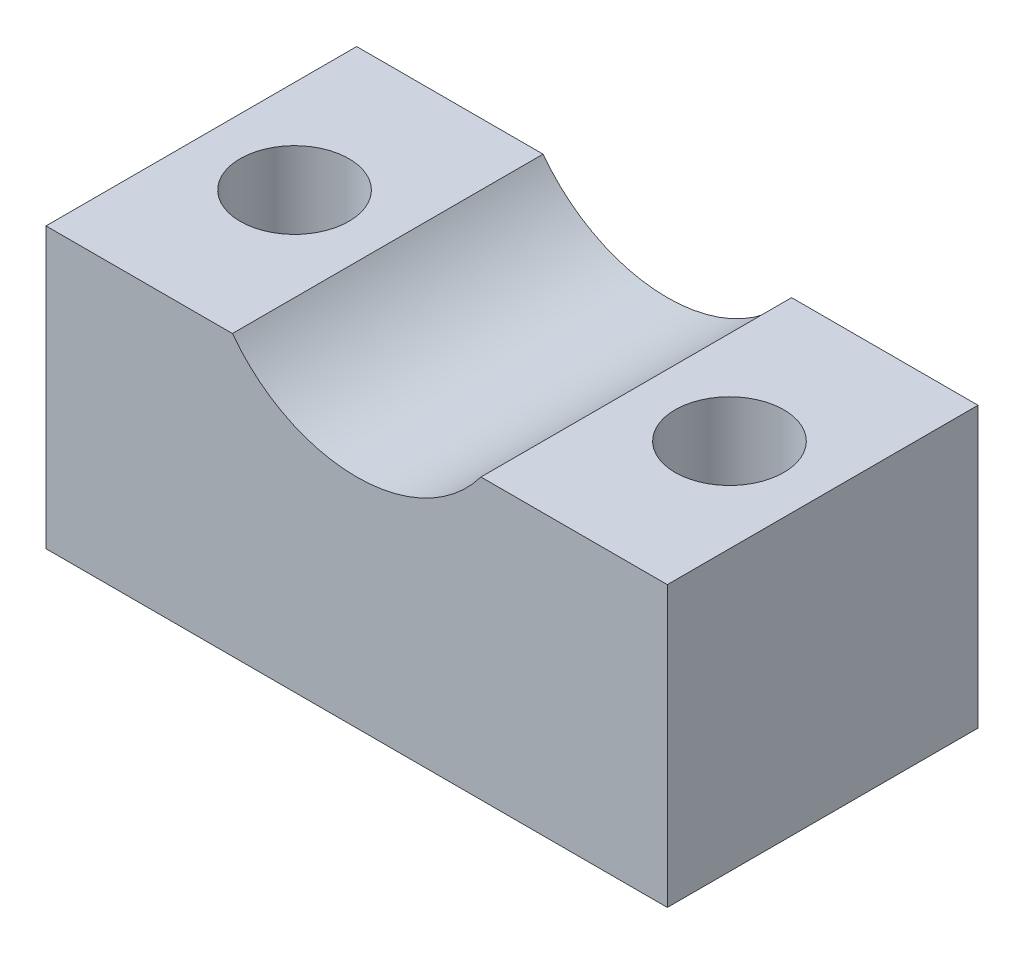
from build123d import *

# Parameters (mm, degrees)
AUFSATZ_LINEAR_AUSTRAGEN1_DEPTH = 10
SKIZZE2_R                       = 1.75
SCHNITT_LINEAR_AUSTRAGEN1_DEPTH = 10


with BuildPart() as part:
    # Skizze1 → Aufsatz-Linear austragen1 (new body)
    with BuildSketch(Plane.XY):
        with BuildLine():
            Line((0, 0), (20, 0))
            Line((20, 0), (20, 9))
            Line((20, 9), (14, 9))
            ThreePointArc((14, 9), (10, 7), (6, 9))
            Line((6, 9), (0, 9))
            Line((0, 9), (0, 0))
        make_face()
    extrude(amount=AUFSATZ_LINEAR_AUSTRAGEN1_DEPTH)

    # Skizze2 → Schnitt-Linear austragen1 (cut, through all)
    with BuildSketch(Plane(origin=(0, 9, 0), x_dir=(1, 0, 0), z_dir=(0, 1, 0))):
        with Locations((3, -5)):
            Circle(SKIZZE2_R)
        with Locations((17, -5)):
            Circle(SKIZZE2_R)
    extrude(amount=-SCHNITT_LINEAR_AUSTRAGEN1_DEPTH, mode=Mode.SUBTRACT)


solid = part.part
